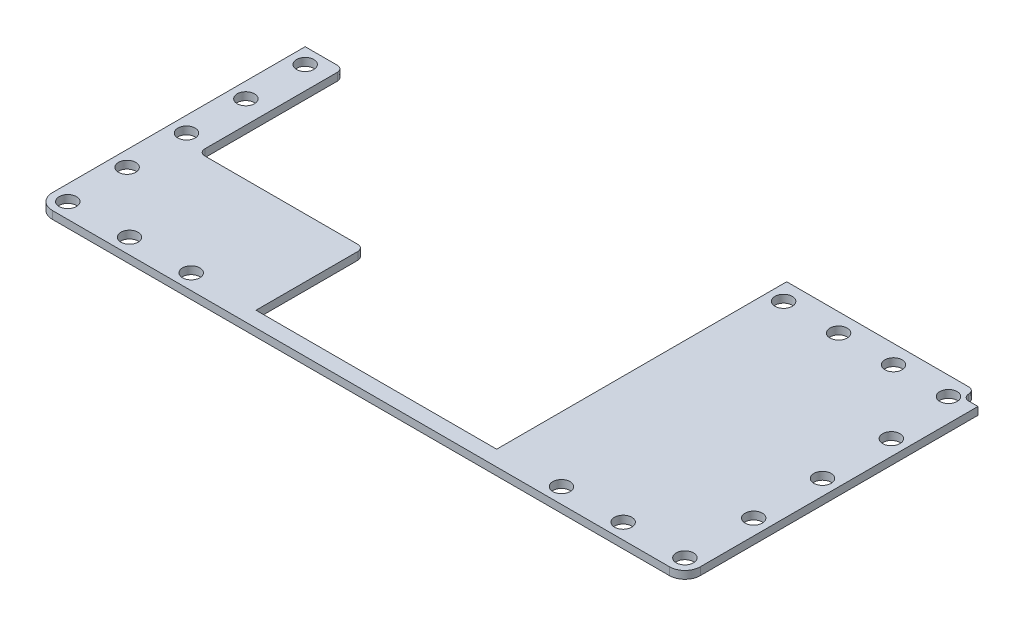
from build123d import *

# Parameters (mm, degrees)
BOSS_EXTRUDE1_DEPTH     = 1.5875
SKETCH2_R               = 1.778
CUT_EXTRUDE1_DEPTH      = 1
CUT_EXTRUDE1_DEPTH_BACK = 2.5875
FILLET1_R               = 1.27
SKETCH3_W               = 34.036
SKETCH3_H               = 12.7
CUT_EXTRUDE2_DEPTH      = 1
CUT_EXTRUDE2_DEPTH_BACK = 2.5875
FILLET2_R               = 1.27


with BuildPart() as part:
    # Sketch1 → Boss-Extrude1 (new body)
    with BuildSketch(Plane(origin=(0, 0, 0), x_dir=(1, 0, 0), z_dir=(0, 1, 0))):
        with BuildLine():
            Line((-66.675, 3.175), (-66.675, 55.209357386))
            Line((-66.675, 55.209357386), (-58.801, 55.209357386))
            Line((-58.801, 55.209357386), (-58.801, 36.83))
            Line((-58.801, 36.83), (-24.765, 36.83))
            Line((-24.765, 36.83), (-24.765, 3.175))
            Line((-24.765, 3.175), (24.765, 3.175))
            Line((24.765, 3.175), (24.765, 62.865))
            Line((24.765, 62.865), (62.23, 62.865))
            ThreePointArc((62.23, 62.865), (63.128025612, 62.493025612), (63.5, 61.595))
            ThreePointArc((63.5, 61.595), (63.871974388, 60.696974388), (64.77, 60.325))
            Line((64.77, 60.325), (66.675, 60.325))
            Line((66.675, 60.325), (66.675, 3.175))
            ThreePointArc((66.675, 3.175), (65.74506403, 0.92993597), (63.5, 0))
            Line((63.5, 0), (-63.5, 0))
            ThreePointArc((-63.5, 0), (-65.74506403, 0.92993597), (-66.675, 3.175))
        make_face()
    extrude(amount=BOSS_EXTRUDE1_DEPTH)

    # Sketch2 → Cut-Extrude1 (cut, two sides)
    with BuildSketch(Plane(origin=(0, 1.5875, 0), x_dir=(-1, 0, 0), z_dir=(0, 1, 0))) as cut_extrude1_sk:
        with Locations((63.5, -3.175)):
            Circle(SKETCH2_R)
        with Locations((50.8, -3.175)):
            Circle(SKETCH2_R)
        with Locations((38.1, -3.175)):
            Circle(SKETCH2_R)
        with Locations((-38.1, -3.175)):
            Circle(SKETCH2_R)
        with Locations((-50.8, -3.175)):
            Circle(SKETCH2_R)
        with Locations((-63.5, -3.175)):
            Circle(SKETCH2_R)
        with Locations((63.5, -15.389839347)):
            Circle(SKETCH2_R)
        with Locations((63.5, -27.604678693)):
            Circle(SKETCH2_R)
        with Locations((63.5, -39.81951804)):
            Circle(SKETCH2_R)
        with Locations((63.5, -52.034357386)):
            Circle(SKETCH2_R)
        with Locations((-63.5, -17.337603912)):
            Circle(SKETCH2_R)
        with Locations((-63.5, -31.500207823)):
            Circle(SKETCH2_R)
        with Locations((-63.5, -45.662811735)):
            Circle(SKETCH2_R)
        with Locations((-61.869746345, -59.055)):
            Circle(SKETCH2_R)
        with Locations((-50.559830897, -59.055)):
            Circle(SKETCH2_R)
        with Locations((-39.249915448, -59.055)):
            Circle(SKETCH2_R)
        with Locations((-27.94, -59.055)):
            Circle(SKETCH2_R)
    extrude(amount=CUT_EXTRUDE1_DEPTH, mode=Mode.SUBTRACT)
    extrude(cut_extrude1_sk.sketch, amount=-CUT_EXTRUDE1_DEPTH_BACK, mode=Mode.SUBTRACT)

    # Fillet1
    fillet1_edges = [part.edges().sort_by_distance(p)[0] for p in [
        (-58.801, 0.79375, -55.209357386),
        (-58.801, 0.79375, -36.83),
        (-24.765, 0.79375, -36.83),
    ]]
    fillet(fillet1_edges, radius=FILLET1_R)

    # Sketch3 → Cut-Extrude2 (cut, two sides)
    with BuildSketch(Plane(origin=(0, 1.5875, 0), x_dir=(1, 0, 0), z_dir=(0, 1, 0))) as cut_extrude2_sk:
        with Locations((-41.783, 31.75)):
            Rectangle(SKETCH3_W, SKETCH3_H)
    extrude(amount=CUT_EXTRUDE2_DEPTH, mode=Mode.SUBTRACT)
    extrude(cut_extrude2_sk.sketch, amount=-CUT_EXTRUDE2_DEPTH_BACK, mode=Mode.SUBTRACT)

    # Fillet2
    fillet2_edges = [part.edges().sort_by_distance(p)[0] for p in [
        (-24.765, 0.79375, -25.4),
        (-58.801, 0.79375, -25.4),
    ]]
    fillet(fillet2_edges, radius=FILLET2_R)


solid = part.part
